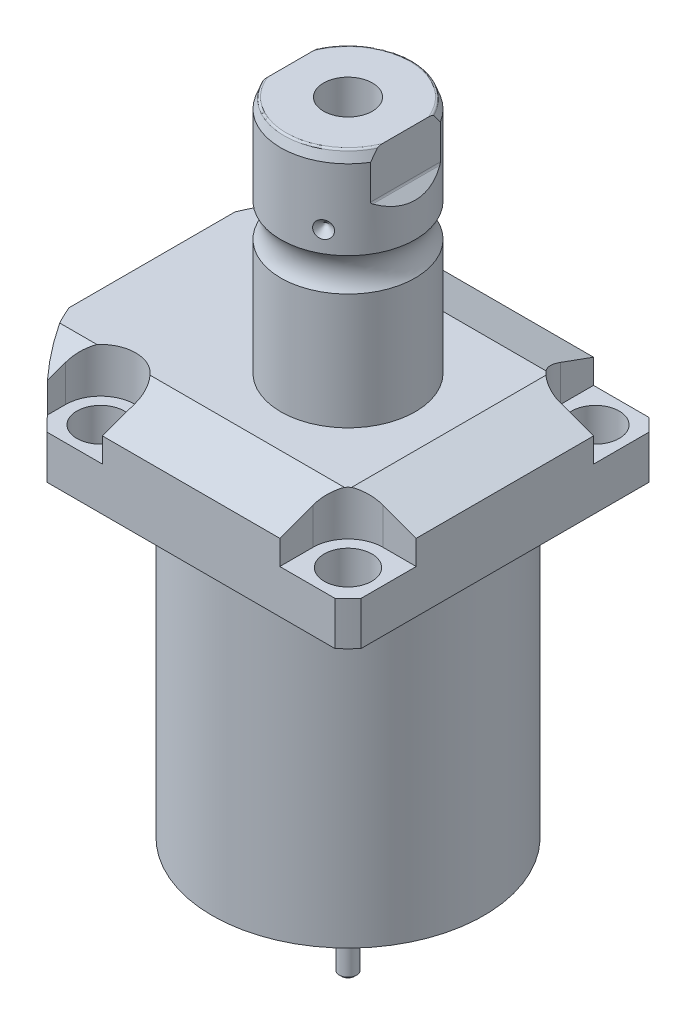
from build123d import *

# Parameters (mm, degrees)
SKETCH1_W               = 88.9
SKETCH1_H               = 100
EXTRUDE1_DEPTH          = 113.919
SKETCH2_OUTSIDE_W       = 137.146
SKETCH2_OUTSIDE_H       = 126.046
SKETCH2_OUTSIDE_R       = 60.325
CUT_EXTRUDE1_DEPTH      = 114.919
SKETCH3_W               = 38.1002
SKETCH3_H               = 88.9
FILLET1_R               = 0.381
CUT_EXTRUDE2_DEPTH      = 12.7
CUT_EXTRUDE9_START      = -56.55
CUT_EXTRUDE9_DEPTH      = 102
CUT_EXTRUDE7_DEPTH      = 45.45
CUT_EXTRUDE7_DEPTH_BACK = 45.45
SKETCH10_R              = 1.1811
SKETCH11_R              = 1.1811
LPATTERN1_COUNT         = 2
LPATTERN1_PITCH         = 25.9588
CUT_EXTRUDE8_DEPTH      = 53.34
SKETCH17_W              = 6.7435
SKETCH17_H              = 12.319
HOLE1_AT_2_COUNT        = 2
HOLE1_AT_2_PITCH        = 70.104
HOLE1_AT_3_COUNT        = 2
HOLE1_AT_3_PITCH        = 99.142027577
HOLE1_AT_4_COUNT        = 2
HOLE1_AT_4_PITCH        = 70.104
CHAMFER1_SIZE           = 0.635
FILLET2_R               = 0.635
CIRPATTERN1_COUNT       = 3
CUT_EXTRUDE10_DEPTH     = 3.81000762
SKETCH25_W              = 2.70510541
SKETCH25_H              = 1.320802642
SKETCH26_R              = 1.27000254
CUT_EXTRUDE11_DEPTH     = 7.62001524


with BuildPart() as part:
    # Sketch1 → Extrude1 (new body)
    with BuildSketch(Plane.ZX):
        with Locations((0, -5.55)):
            Rectangle(SKETCH1_W, SKETCH1_H)
    extrude(amount=EXTRUDE1_DEPTH)

    # Sketch2 outside → Cut-Extrude1 (cut, through all)
    with BuildSketch(Plane.XZ):
        with Locations((-5.55, 0)):
            Rectangle(SKETCH2_OUTSIDE_W, SKETCH2_OUTSIDE_H)
        Circle(SKETCH2_OUTSIDE_R, mode=Mode.SUBTRACT)
    extrude(amount=-CUT_EXTRUDE1_DEPTH, mode=Mode.SUBTRACT)

    # Sketch3 → Cut-Revolve1 (revolve, cut)
    with BuildSketch(Plane(origin=(0, 0, 0), x_dir=(0, 0, 1), z_dir=(1, 0, 0))):
        with Locations((57.5436, -44.45)):
            Rectangle(SKETCH3_W, SKETCH3_H)
    revolve(axis=Axis((0, 93.345, 0), (0, -1, 0)), mode=Mode.SUBTRACT)

    # Fillet1
    fillet1_edges = [part.edges().sort_by_distance(p)[0] for p in [
        (0, 88.9, -38.4935),
    ]]
    fillet(fillet1_edges, radius=FILLET1_R)

    # Sketch4 → Cut-Extrude2 (cut)
    with BuildSketch(Plane(origin=(0, 113.919, 0), x_dir=(-1, 0, 0), z_dir=(0, 1, 0))):
        with BuildLine():
            Line((-25.121, -44.45), (-25.121, -35.052))
            ThreePointArc((-25.121, -35.052), (-28.029722556, -28.029722556), (-35.052, -25.121))
            Line((-35.052, -25.121), (-44.45, -25.121))
            Line((-44.45, -25.121), (-44.45, -44.45))
            Line((-44.45, -44.45), (-25.121, -44.45))
        make_face()
        with BuildLine():
            Line((44.983, -44.45), (25.121, -44.45))
            Line((25.121, -44.45), (25.121, -35.052))
            ThreePointArc((25.121, -35.052), (35.052, -25.121), (44.983, -35.052))
            Line((44.983, -35.052), (44.983, -44.45))
        make_face()
        with BuildLine():
            Line((25.121, 44.45), (25.121, 35.052))
            ThreePointArc((25.121, 35.052), (35.052, 25.121), (44.983, 35.052))
            Line((44.983, 35.052), (44.983, 44.45))
            Line((44.983, 44.45), (25.121, 44.45))
        make_face()
        with BuildLine():
            Line((-35.052, 25.121), (-44.45, 25.121))
            Line((-44.45, 25.121), (-44.45, 44.45))
            Line((-44.45, 44.45), (-25.121, 44.45))
            Line((-25.121, 44.45), (-25.121, 35.052))
            ThreePointArc((-25.121, 35.052), (-28.029722556, 28.029722556), (-35.052, 25.121))
        make_face()
    extrude(amount=-CUT_EXTRUDE2_DEPTH, mode=Mode.SUBTRACT)

    # Sketch5 → Cut-Extrude9 (cut)
    with BuildSketch(Plane(origin=(0, 0, 0), x_dir=(0, 0, -1), z_dir=(1, 0, 0)).offset(CUT_EXTRUDE9_START)):
        Polygon((-28.575, 113.919), (-44.45, 108.140972531), (-44.45, 113.919), align=None)
    cut_extrude9 = extrude(amount=CUT_EXTRUDE9_DEPTH, mode=Mode.SUBTRACT)

    # Mirror1: Cut-Extrude9 across plane
    add(cut_extrude9.mirror(Plane.XY), mode=Mode.SUBTRACT)

    # Sketch9 → Cut-Extrude7 (cut, two sides)
    with BuildSketch(Plane.XY) as cut_extrude7_sk:
        Polygon((28.575, 113.919), (44.45, 108.140972531), (44.45, 113.919), align=None)
    extrude(amount=CUT_EXTRUDE7_DEPTH, mode=Mode.SUBTRACT)
    extrude(cut_extrude7_sk.sketch, amount=-CUT_EXTRUDE7_DEPTH_BACK, mode=Mode.SUBTRACT)

    # Sketch20 → Cut-Revolve4 (revolve, cut)
    with BuildSketch(Plane(origin=(-41.402, 88.9, -18.1102), x_dir=(0, 1, 0), z_dir=(1, 0, 0)), mode=Mode.PRIVATE) as cut_revolve4_sk:
        Polygon((0, 41.9225), (1.4478, 41.9225), (1.4478, 39.4714), (2.4638, 39.4714), (2.4638, 37.4648), (13.4366, 37.4648), (13.4366, 36.2202), (0, 36.2202), align=None)
    cut_revolve4 = revolve(cut_revolve4_sk.sketch.rotate(Axis((-41.402, 81.620304954, 18.11), (0, 1, 0)), 180), axis=Axis((-41.402, 81.620304954, 18.11), (0, 1, 0)), mode=Mode.SUBTRACT)  # turned: the seam where the file's is

    # Mirror10: Cut-Revolve4 across plane
    add(cut_revolve4.mirror(Plane.XY), mode=Mode.SUBTRACT)

    # S2D0007 → Cut-Revolve2 (revolve, cut)
    with BuildSketch(Plane(origin=(-55.5498, 101.9048, 12.9794), x_dir=(0, 1, 0), z_dir=(0, 0, 1)), mode=Mode.PRIVATE) as cut_revolve2_sk:
        Polygon((0.0002, 0.0002), (10.7444, 0.0002), (10.7444, -0.2538), (6.655, -0.2538), (5.9438, -0.965), (5.9438, -14.427), (0.0002, -14.427), align=None)
    cut_revolve2 = revolve(cut_revolve2_sk.sketch.rotate(Axis((-40.6146, 101.905, 12.9794), (-1, 0, 0)), 90), axis=Axis((-40.6146, 101.905, 12.9794), (-1, 0, 0)), mode=Mode.SUBTRACT)  # turned: the seam where the file's is

    # LPattern1: Cut-Revolve2 ×2
    with Locations(*[(0, 0, -i * LPATTERN1_PITCH) for i in range(1, LPATTERN1_COUNT)]):
        add(cut_revolve2, mode=Mode.SUBTRACT)

    # Sketch15 → Revolve3 (revolve)
    with BuildSketch(Plane(origin=(0, 0, 0), x_dir=(0, -1, 0), z_dir=(1, 0, 0)), mode=Mode.PRIVATE) as revolve3_sk:
        with BuildLine():
            Line((-113.919, 0), (-113.919, 19.05))
            Line((-113.919, 19.05), (-146.752705156, 19.05))
            ThreePointArc((-146.752705156, 19.05), (-151.46, 17.5005), (-156.167294844, 19.05))
            Line((-156.167294844, 19.05), (-178.714, 19.05))
            Line((-178.714, 19.05), (-181.635, 17.986842946))
            Line((-181.635, 17.986842946), (-181.635, 0))
            Line((-181.635, 0), (-113.919, 0))
        make_face()
    revolve(revolve3_sk.sketch.rotate(Axis((0, 197.63613, 0), (0, -1, 0)), 180), axis=Axis((0, 197.63613, 0), (0, -1, 0)))  # turned: the seam where the file's is

    # Sketch16 → Cut-Extrude8 (cut, symmetric)
    with BuildSketch(Plane(origin=(0, 0, 0), x_dir=(0, -1, 0), z_dir=(0, 0, 1))):
        with BuildLine():
            Line((-181.635, 19.05), (-165.850869265, 19.05))
            Line((-165.850869265, 19.05), (-168.396184633, 16.504684633))
            ThreePointArc((-168.396184633, 16.504684633), (-168.643395225, 16.339503796), (-168.935, 16.2815))
            Line((-168.935, 16.2815), (-181.635, 16.2815))
            Line((-181.635, 16.2815), (-181.635, 19.05))
        make_face()
        with BuildLine():
            Line((-181.635, -19.05), (-181.635, -16.2815))
            Line((-181.635, -16.2815), (-168.935, -16.2815))
            ThreePointArc((-168.935, -16.2815), (-168.643395225, -16.339503796), (-168.396184633, -16.504684633))
            Line((-168.396184633, -16.504684633), (-165.850869265, -19.05))
            Line((-165.850869265, -19.05), (-181.635, -19.05))
        make_face()
    extrude(amount=CUT_EXTRUDE8_DEPTH, both=True, mode=Mode.SUBTRACT)

    # Sketch17 → Hole1 (revolve, cut)
    with BuildSketch(Plane(origin=(35.052, 101.219, -35.052), x_dir=(0, 0, 1), z_dir=(1, 0, 0))):
        with Locations((3.37175, 6.1595)):
            Rectangle(SKETCH17_W, SKETCH17_H)
    hole1 = revolve(axis=Axis((35.052, -8.781, -35.052), (0, 1, 0)), mode=Mode.SUBTRACT)

    # Hole1 at 2: Hole1 ×2
    with Locations(*[(0, 0, i * HOLE1_AT_2_PITCH) for i in range(1, HOLE1_AT_2_COUNT)]):
        add(hole1, mode=Mode.SUBTRACT)

    # Hole1 at 3: Hole1 ×2
    with Locations(*[Vector(-0.707106781, 0, 0.707106781) * (i * HOLE1_AT_3_PITCH) for i in range(1, HOLE1_AT_3_COUNT)]):
        add(hole1, mode=Mode.SUBTRACT)

    # Hole1 at 4: Hole1 ×2
    with Locations(*[(-i * HOLE1_AT_4_PITCH, 0, 0) for i in range(1, HOLE1_AT_4_COUNT)]):
        add(hole1, mode=Mode.SUBTRACT)

    # Chamfer1
    chamfer1_edges = [part.edges().sort_by_distance(p)[0] for p in [
        (-41.402, 91.3638, 19.3546),
        (-41.402, 91.3638, -19.3546),
    ]]
    chamfer(chamfer1_edges, length=CHAMFER1_SIZE)

    # Sketch21 → Cut-Revolve5 (revolve, cut)
    with BuildSketch(Plane.XY, mode=Mode.PRIVATE) as cut_revolve5_sk:
        Polygon((0, 152.068512296), (6.9342, 156.235), (6.9342, 181.635), (0, 181.635), align=None)
    revolve(cut_revolve5_sk.sketch.rotate(Axis((0, 0, 0), (0, 1, 0)), 270), axis=Axis((0, 0, 0), (0, 1, 0)), mode=Mode.SUBTRACT)  # turned: the seam where the file's is

    # Fillet2
    fillet2_edges = [part.edges().sort_by_distance(p)[0] for p in [
        (0, 181.635, -17.986842946),
        (0, 181.635, 17.986842946),
    ]]
    fillet(fillet2_edges, radius=FILLET2_R)

    # Sketch22 → Cut-Revolve6 (revolve, cut)
    with BuildSketch(Plane.XY, mode=Mode.PRIVATE) as cut_revolve6_sk:
        Polygon((-19.05, 164.541), (-16.637, 162.128), (-19.05, 162.128), align=None)
    cut_revolve6 = revolve(cut_revolve6_sk.sketch.rotate(Axis((-37.997376206, 162.128, 0), (1, 0, 0)), 90), axis=Axis((-37.997376206, 162.128, 0), (1, 0, 0)), mode=Mode.SUBTRACT)  # turned: the seam where the file's is

    # CirPattern1: Cut-Revolve6 ×3 about axis
    cirpattern1_axis = Axis((0, 197.63613, 0), (0, 1, 0))
    for i in range(1, CIRPATTERN1_COUNT):
        add(cut_revolve6.rotate(cirpattern1_axis, i * 360 / CIRPATTERN1_COUNT), mode=Mode.SUBTRACT)

    # Sketch23 → Revolve5 (revolve)
    with BuildSketch(Plane(origin=(0, 0, 0), x_dir=(0, 0, -1), z_dir=(1, 0, 0)), mode=Mode.PRIVATE) as revolve5_sk:
        Polygon((0, 0), (3.17500635, 0), (3.17500635, -19.841076991), (2.438404877, -21.116908167), (2.438404877, -32.63982855), (1.803403607, -33.27482982), (0, -33.27482982), align=None)
    revolve(revolve5_sk.sketch.rotate(Axis((0, -1000, 0), (0, 1, 0)), 180), axis=Axis((0, -1000, 0), (0, 1, 0)))  # turned: the seam where the file's is

    # Sketch24 → Cut-Extrude10 (cut, symmetric)
    with BuildSketch(Plane(origin=(0, 0, 0), x_dir=(0, 0, -1), z_dir=(1, 0, 0))):
        Polygon((3.17500635, -16.726696723), (2.501905004, -17.39979807), (2.501905004, -33.27482982), (3.17500635, -33.27482982), align=None)
        Polygon((-3.17500635, -33.27482982), (-2.501905004, -33.27482982), (-2.501905004, -17.39979807), (-3.17500635, -16.726696723), align=None)
    extrude(amount=CUT_EXTRUDE10_DEPTH, both=True, mode=Mode.SUBTRACT)

    # Sketch25 → Cut-Revolve7 (revolve, cut)
    with BuildSketch(Plane(origin=(0, 0, 0), x_dir=(0, 0, -1), z_dir=(1, 0, 0)), mode=Mode.PRIVATE) as cut_revolve7_sk:
        with Locations((12.998475997, 0.660401321)):
            Rectangle(SKETCH25_W, SKETCH25_H)
    revolve(cut_revolve7_sk.sketch.rotate(Axis((0, -1000, 0), (0, 1, 0)), 218.00100076), axis=Axis((0, -1000, 0), (0, 1, 0)), mode=Mode.SUBTRACT)  # turned: the seam where the file's is

    # Sketch26 → Cut-Extrude11 (cut)
    with BuildSketch(Plane.XZ):
        with Locations(Location((19.431038862, 0, 0), (0, 0, 270))):  # turned: the seam where the file's is
            Circle(SKETCH26_R)
        with Locations(Location((18.768942269, -5.029122924, 0), (0, 0, 270))):  # turned: the seam where the file's is
            Circle(SKETCH26_R)
        with Locations(Location((-13.739819345, 13.739819345, 0), (0, 0, 90))):  # turned: the seam where the file's is
            Circle(SKETCH26_R)
        with Locations(Location((-9.715519431, 16.827773276, 0), (0, 0, 90))):  # turned: the seam where the file's is
            Circle(SKETCH26_R)
        with Locations(Location((-13.739819345, -13.739819345, 0), (0, 0, 270))):  # turned: the seam where the file's is
            Circle(SKETCH26_R)
        with Locations(Location((-9.715519431, -16.827773276, 0), (0, 0, 270))):  # turned: the seam where the file's is
            Circle(SKETCH26_R)
    extrude(amount=-CUT_EXTRUDE11_DEPTH, mode=Mode.SUBTRACT)


with BuildPart() as body_2:
    # Sketch10 → Revolve4 (revolve)
    with BuildSketch(Plane(origin=(-41.402, 88.9, -18.1102), x_dir=(0, 1, 0), z_dir=(1, 0, 0))):
        with Locations((0.2667, 4.5214)):
            Circle(SKETCH10_R)
    revolve(axis=Axis((-41.402, 87.86749, -18.11), (0, 1, 0)))


with BuildPart() as body_3:
    # Sketch11 → Revolve2 (revolve)
    with BuildSketch(Plane(origin=(-41.402, 88.9, 18.1102), x_dir=(0, 1, 0), z_dir=(1, 0, 0)), mode=Mode.PRIVATE) as revolve2_sk:
        with Locations((0.2667, 4.521)):
            Circle(SKETCH11_R)
    revolve(revolve2_sk.sketch.rotate(Axis((-41.402, 87.86749, 18.11), (0, 1, 0)), 180), axis=Axis((-41.402, 87.86749, 18.11), (0, 1, 0)))  # turned: the seam where the file's is


solid = Compound([part.part, body_2.part, body_3.part])
